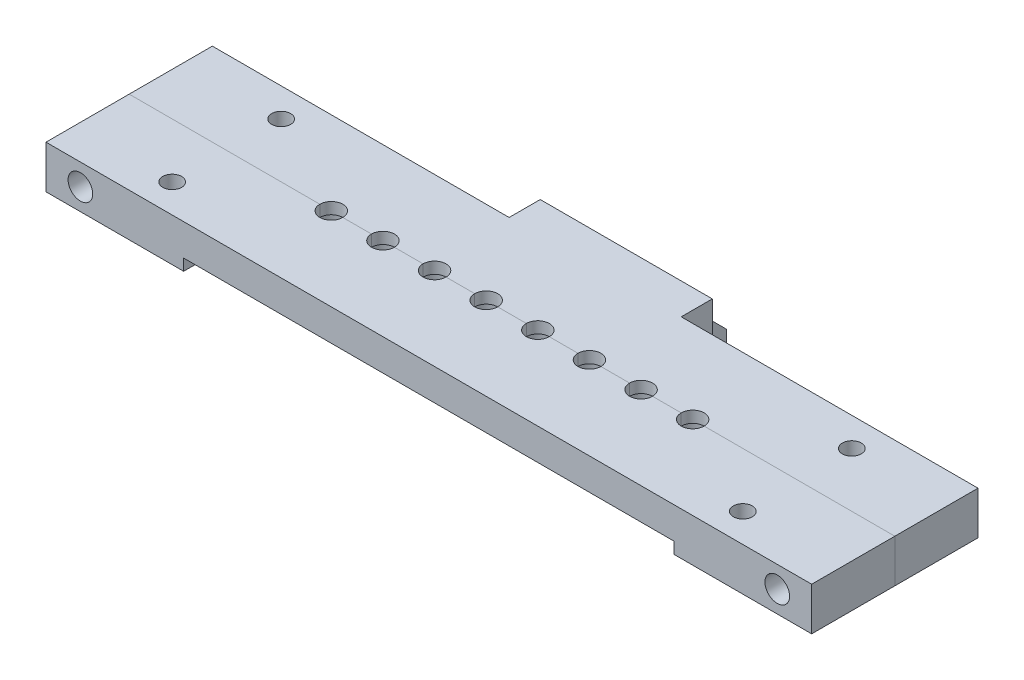
from build123d import *

# Parameters (mm, degrees)
BOSS_EXTRUDE1_DEPTH      = 14.5
LPATTERN1_COUNT          = 8
LPATTERN1_PITCH          = 9
SKETCH4_R                = 1.65
CUT_EXTRUDE1_DEPTH       = 7.5
SKETCH5_W                = 85.48
SKETCH5_H                = 5
CUT_EXTRUDE2_DEPTH       = 2
SKETCH7_W                = 12
SKETCH7_H                = 7.5
SKETCH7_R                = 2.15
BOSS_EXTRUDE2_DEPTH      = 29
SKETCH8_W                = 30
SKETCH8_H                = 5.5
BOSS_EXTRUDE3_DEPTH      = 5.419987
SKETCH9_W                = 30
SKETCH9_H                = 5.419986991
BOSS_EXTRUDE4_DEPTH      = 19.91352
SKETCH10_W               = 5.419986991
SKETCH10_H               = 5
BOSS_EXTRUDE5_DEPTH      = 20
BOSS_EXTRUDE5_DEPTH_BACK = 50
SKETCH11_R               = 1.65
CUT_EXTRUDE3_DEPTH       = 5
SKETCH12_W               = 10
SKETCH12_H               = 5
BOSS_EXTRUDE6_DEPTH      = 5
SKETCH13_W               = 10
SKETCH13_H               = 5
BOSS_EXTRUDE7_DEPTH      = 5
CHAMFER1_SIZE            = 10
BOSS_EXTRUDE8_DEPTH      = 5
SKETCH15_R               = 1.65
CUT_EXTRUDE4_DEPTH       = 5


with BuildPart() as part:
    # Sketch1 → Boss-Extrude1 (new body, symmetric)
    with BuildSketch(Plane.XY):
        Polygon((-54.74, -3.75), (-35.4, -3.75), (-35.4, -2.25), (-33.5, -2.25), (-33.5, -1.25), (-34.25, -1.25), (-34.25, 1.75), (-33.5, 1.75), (-33.5, 3.75), (-54.74, 3.75), align=None)
        Polygon((-35.4, -3.75), (54.74, -3.75), (54.74, 3.75), (-33.5, 3.75), (-33.5, 1.75), (-34.25, 1.75), (-34.25, -1.25), (-33.5, -1.25), (-33.5, -2.25), (-35.4, -2.25), align=None)
    extrude(amount=BOSS_EXTRUDE1_DEPTH, both=True)

    # Sketch2 → Cut-Revolve2 (revolve, cut)
    with BuildSketch(Plane.XY):
        Polygon((-31.5, 3.75), (-31.5, -3.75), (-35.4, -3.75), (-35.4, -2.25), (-33.5, -2.25), (-33.5, -1.25), (-34.25, -1.25), (-34.25, 1.75), (-33.5, 1.75), (-33.5, 3.75), align=None)
    cut_revolve2 = revolve(axis=Axis((-31.5, 3.75, 0), (0, -1, 0)), mode=Mode.SUBTRACT)

    # LPattern1: Cut-Revolve2 ×8
    with Locations(*[(i * LPATTERN1_PITCH, 0, 0) for i in range(1, LPATTERN1_COUNT)]):
        add(cut_revolve2, mode=Mode.SUBTRACT)

    # Sketch4 → Cut-Extrude1 (cut)
    with BuildSketch(Plane(origin=(0, 3.75, 0), x_dir=(1, 0, 0), z_dir=(0, 1, 0))):
        with Locations((-49.74, 9.5)):
            Circle(SKETCH4_R)
        with Locations((49.74, 9.5)):
            Circle(SKETCH4_R)
        with Locations((49.74, -9.5)):
            Circle(SKETCH4_R)
        with Locations((-49.74, -9.5)):
            Circle(SKETCH4_R)
    extrude(amount=-CUT_EXTRUDE1_DEPTH, mode=Mode.SUBTRACT)

    # Sketch5 → Cut-Extrude2 (cut)
    with BuildSketch(Plane.XZ.offset(3.75)):
        with Locations((0, 12)):
            Rectangle(SKETCH5_W, SKETCH5_H)
        with Locations((0, -12)):
            Rectangle(SKETCH5_W, SKETCH5_H)
    extrude(amount=-CUT_EXTRUDE2_DEPTH, mode=Mode.SUBTRACT)

    # Sketch7 → Boss-Extrude2 (add)
    with BuildSketch(Plane(origin=(0, 0, -14.5), x_dir=(-1, 0, 0), z_dir=(0, 0, -1))):
        with Locations((-60.74, 0)):
            Rectangle(SKETCH7_W, SKETCH7_H)
        with Locations((-60.74, 0)):
            Circle(SKETCH7_R, mode=Mode.SUBTRACT)
        with Locations((60.74, 0)):
            Rectangle(SKETCH7_W, SKETCH7_H)
        with Locations((60.74, 0)):
            Circle(SKETCH7_R, mode=Mode.SUBTRACT)
    extrude(amount=-BOSS_EXTRUDE2_DEPTH)

    # Sketch8 → Boss-Extrude3 (add)
    with BuildSketch(Plane(origin=(0, 0, -14.5), x_dir=(-1, 0, 0), z_dir=(0, 0, -1))):
        with Locations((0, 1)):
            Rectangle(SKETCH8_W, SKETCH8_H)
    extrude(amount=BOSS_EXTRUDE3_DEPTH)

    # Sketch9 → Boss-Extrude4 (add)
    with BuildSketch(Plane.XZ.offset(1.75)):
        with Locations((0, -17.209993496)):
            Rectangle(SKETCH9_W, SKETCH9_H)
    extrude(amount=BOSS_EXTRUDE4_DEPTH)

    # Sketch10 → Boss-Extrude5 (add, two sides)
    with BuildSketch(Plane(origin=(15, 0, 0), x_dir=(0, 0, -1), z_dir=(1, 0, 0))) as boss_extrude5_sk:
        with Locations((17.209993496, -19.16352)):
            Rectangle(SKETCH10_W, SKETCH10_H)
    extrude(amount=BOSS_EXTRUDE5_DEPTH)
    extrude(boss_extrude5_sk.sketch, amount=-BOSS_EXTRUDE5_DEPTH_BACK)

    # Sketch11 → Cut-Extrude3 (cut)
    with BuildSketch(Plane(origin=(0, -16.66352, 0), x_dir=(1, 0, 0), z_dir=(0, 1, 0))):
        with Locations((-30, 17.209993495)):
            Circle(SKETCH11_R)
        with Locations((30, 17.209993495)):
            Circle(SKETCH11_R)
    extrude(amount=-CUT_EXTRUDE3_DEPTH, mode=Mode.SUBTRACT)

    # Sketch12 → Boss-Extrude6 (add)
    with BuildSketch(Plane(origin=(0, 0, -19.919986991), x_dir=(-1, 0, 0), z_dir=(0, 0, -1))):
        with Locations((-30, -19.16352)):
            Rectangle(SKETCH12_W, SKETCH12_H)
        with Locations((30, -19.16352)):
            Rectangle(SKETCH12_W, SKETCH12_H)
    extrude(amount=BOSS_EXTRUDE6_DEPTH)

    # Sketch13 → Boss-Extrude7 (add)
    with BuildSketch(Plane.XY.offset(-14.5)):
        with Locations((-30, -19.16352)):
            Rectangle(SKETCH13_W, SKETCH13_H)
        with Locations((30, -19.16352)):
            Rectangle(SKETCH13_W, SKETCH13_H)
    extrude(amount=BOSS_EXTRUDE7_DEPTH)

    # Chamfer1
    chamfer1_edges = [part.edges().sort_by_distance(p)[0] for p in [
        (-15, -16.66352, -17.209993495),
        (15, -16.66352, -17.209993495),
    ]]
    chamfer(chamfer1_edges, length=CHAMFER1_SIZE)


with BuildPart() as body_2:
    # Split1: the piece on the far side of the plane
    add(part.part)
    split(bisect_by=Plane.XY, keep=Keep.BOTTOM)

    # Sketch14 → Boss-Extrude8 (add, symmetric)
    with BuildSketch(Plane.ZY):
        Polygon((-19.919986991, -6.66352), (-27.419986991, -14.16352), (-27.419986991, -39.66352), (-32.419986991, -39.66352), (-32.419986991, -12.092452188), (-19.919986991, 0.407547812), align=None)
    extrude(amount=BOSS_EXTRUDE8_DEPTH, both=True)

    # Sketch15 → Cut-Extrude4 (cut)
    with BuildSketch(Plane(origin=(0, 0, -32.419986991), x_dir=(-1, 0, 0), z_dir=(0, 0, -1))):
        with Locations((0, -31.66352)):
            Circle(SKETCH15_R)
    extrude(amount=-CUT_EXTRUDE4_DEPTH, mode=Mode.SUBTRACT)


with BuildPart() as part_1:
    add(part.part)

    # Split1
    split(bisect_by=Plane.XY, keep=Keep.TOP)


solid = Compound([body_2.part, part_1.part])
